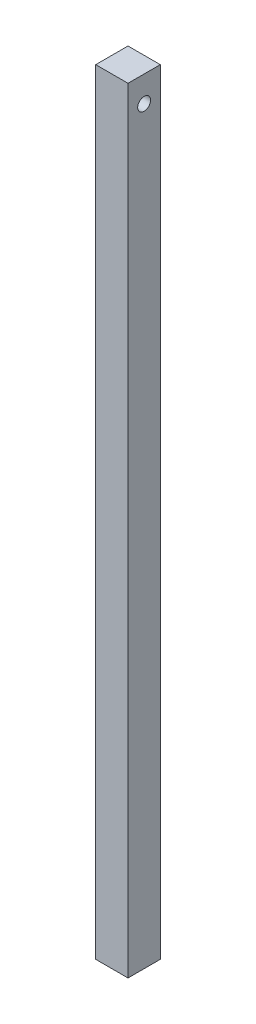
from build123d import *

# Parameters (mm, degrees)
SKETCH1_W                = 25
SKETCH1_H                = 25
BOSS_EXTRUDE1_DEPTH      = 500
BOSS_EXTRUDE1_DEPTH_BACK = 100
SKETCH2_R                = 5
CUT_EXTRUDE1_DEPTH       = 500


with BuildPart() as part:
    # Sketch1 → Boss-Extrude1 (new body, two sides)
    with BuildSketch(Plane(origin=(0, 0, 0), x_dir=(1, 0, 0), z_dir=(0, 1, 0))) as boss_extrude1_sk:
        Rectangle(SKETCH1_W, SKETCH1_H)
    extrude(amount=BOSS_EXTRUDE1_DEPTH)
    extrude(boss_extrude1_sk.sketch, amount=-BOSS_EXTRUDE1_DEPTH_BACK)

    # Sketch2 → Cut-Extrude1 (cut)
    with BuildSketch(Plane.ZY.offset(12.5)):
        with Locations((0, 480)):
            Circle(SKETCH2_R)
    extrude(amount=-CUT_EXTRUDE1_DEPTH, mode=Mode.SUBTRACT)


solid = part.part
